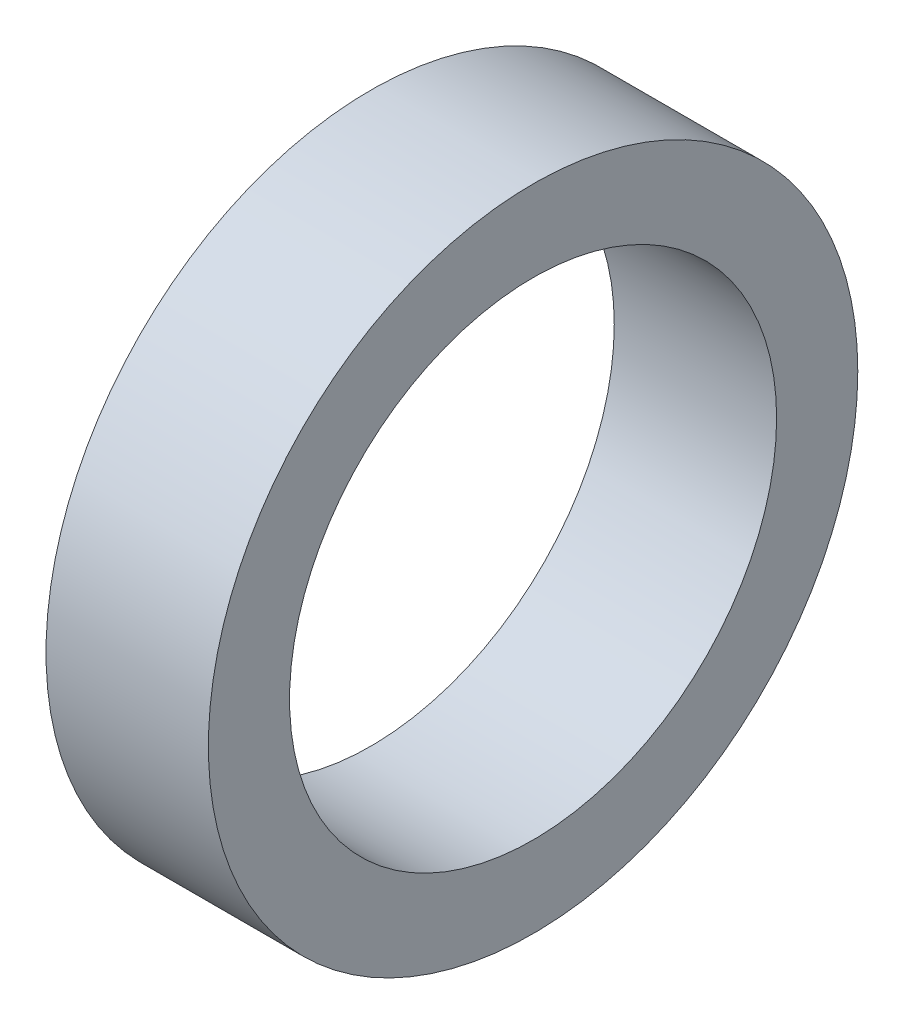
from build123d import *

# Parameters (mm, degrees)
SKETCH3_R           = 12.7
SKETCH3_R_2         = 9.525
BOSS_EXTRUDE1_DEPTH = 3.175


with BuildPart() as part:
    # Sketch3 → Boss-Extrude1 (new body, symmetric)
    with BuildSketch(Plane(origin=(0, 0, 0), x_dir=(0, 0, -1), z_dir=(1, 0, 0))):
        Circle(SKETCH3_R)
        Circle(SKETCH3_R_2, mode=Mode.SUBTRACT)
    extrude(amount=BOSS_EXTRUDE1_DEPTH, both=True)


solid = part.part
